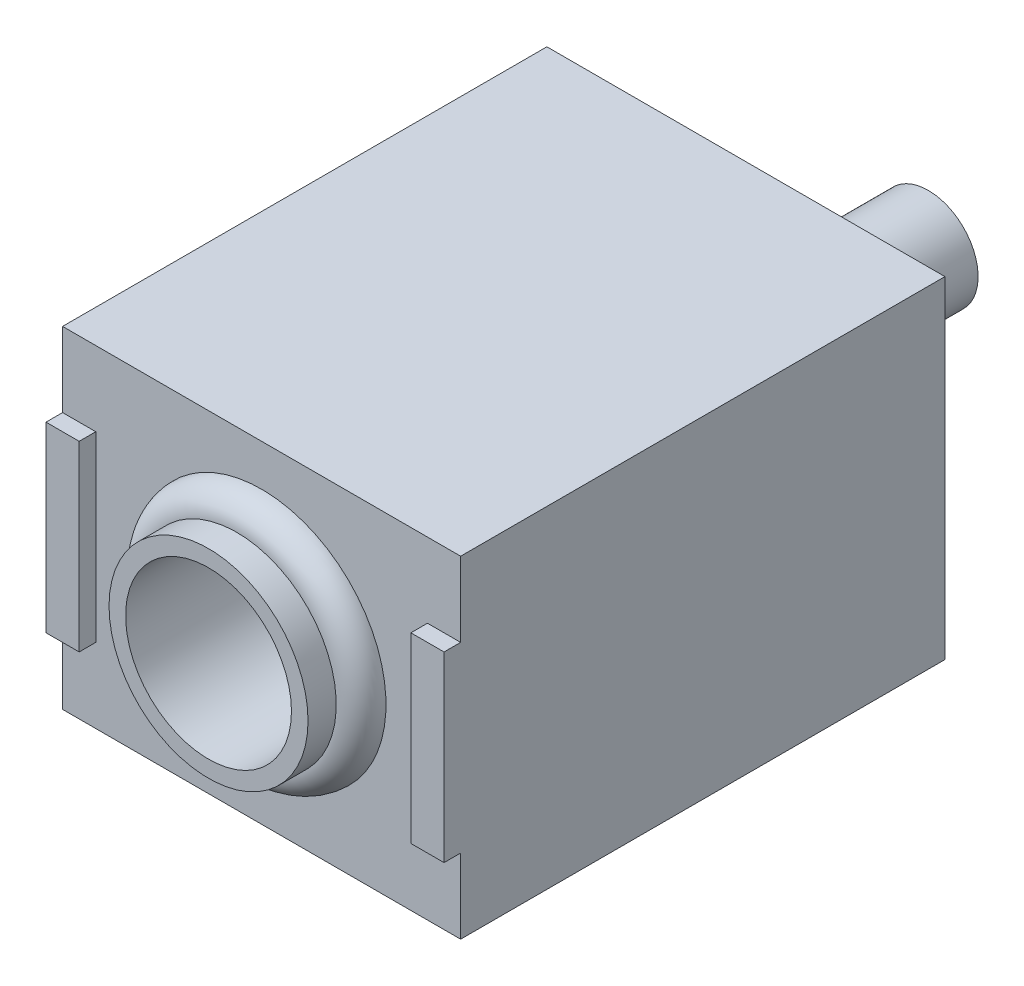
from build123d import *

# Parameters (mm, degrees)
SKETCH1_W           = 12
SKETCH1_H           = 10
BOSS_EXTRUDE1_DEPTH = 14.6
SKETCH2_W           = 1
SKETCH2_H           = 5.5
BOSS_EXTRUDE2_DEPTH = 0.5
SKETCH4_R           = 1.5
BOSS_EXTRUDE3_DEPTH = 5.5
SKETCH5_R           = 2.05
BOSS_EXTRUDE4_DEPTH = 0.5
CUT_EXTRUDE1_DEPTH  = 0.5
SKETCH7_R           = 2.5
CUT_EXTRUDE2_DEPTH  = 11
SKETCH9_R           = 3
SKETCH9_R_2         = 2.5
BOSS_EXTRUDE5_DEPTH = 1.6


with BuildPart() as part:
    # Sketch1 → Boss-Extrude1 (new body)
    with BuildSketch(Plane.XY):
        Rectangle(SKETCH1_W, SKETCH1_H)
    extrude(amount=BOSS_EXTRUDE1_DEPTH)

    # Sketch2 → Boss-Extrude2 (add)
    with BuildSketch(Plane.XY.offset(14.6)):
        with Locations((-5.5, 0)):
            Rectangle(SKETCH2_W, SKETCH2_H)
        with Locations((5.5, 0)):
            Rectangle(SKETCH2_W, SKETCH2_H)
    extrude(amount=BOSS_EXTRUDE2_DEPTH)

    # Sketch4 → Boss-Extrude3 (add)
    with BuildSketch(Plane(origin=(0, 0, 0), x_dir=(-1, 0, 0), z_dir=(0, 0, -1))):
        Circle(SKETCH4_R)
    extrude(amount=BOSS_EXTRUDE3_DEPTH)

    # Sketch5 → Boss-Extrude4 (add)
    with BuildSketch(Plane(origin=(0, 0, 0), x_dir=(-1, 0, 0), z_dir=(0, 0, -1))):
        Circle(SKETCH5_R)
    extrude(amount=BOSS_EXTRUDE4_DEPTH)

    # Sketch6 → Cut-Extrude1 (cut)
    with BuildSketch(Plane(origin=(0, 0, 0), x_dir=(-1, 0, 0), z_dir=(0, 0, -1))):
        with BuildLine():
            Line((-5.022000054, 4.19344844), (-4.356935952, 4.19344844))
            Line((-4.356935952, 4.19344844), (-3.752769285, 2.614121517))
            Line((-3.752769285, 2.614121517), (-3.198682747, 4.19344844))
            Line((-3.198682747, 4.19344844), (-2.534820567, 4.19344844))
            Line((-2.534820567, 4.19344844), (-2.534820567, 4.090884337))
            Line((-2.534820567, 4.090884337), (-2.697080183, 4.090884337))
            add(Edge.make_bspline(
                [(-2.697080183, 4.090884337), (-2.710316809, 4.090636556), (-2.734492679, 4.090183998), (-2.76728752, 4.085652982), (-2.793244282, 4.077989549), (-2.813274161, 4.066597021), (-2.826894921, 4.049870677), (-2.8359508, 4.029264042), (-2.841554988, 4.004099098), (-2.842176045, 3.985816116), (-2.842512875, 3.975900363)],
                knots=[0, 0, 0, 0, 1.461409083, 2.669172297, 3.644102285, 4.438396511, 5.171145089, 5.982913306, 6.9060355, 8, 8, 8, 8], degree=3))
            Line((-2.842512875, 3.975900363), (-2.842512875, 2.394570235))
            add(Edge.make_bspline(
                [(-2.842512875, 2.394570235), (-2.842050819, 2.387038144), (-2.841173668, 2.372739479), (-2.834447891, 2.352433769), (-2.823099881, 2.334952111), (-2.806557353, 2.320282642), (-2.784561689, 2.309069969), (-2.756555778, 2.301303429), (-2.722335078, 2.296750977), (-2.697362885, 2.296271709), (-2.683859029, 2.296012542)],
                knots=[0, 0, 0, 0, 0.852734016, 1.618801414, 2.395714484, 3.189123744, 4.096684287, 5.169862416, 6.469586829, 8, 8, 8, 8], degree=3))
            Line((-2.683859029, 2.296012542), (-2.534820567, 2.296012542))
            Line((-2.534820567, 2.296012542), (-2.534820567, 2.19344844))
            Line((-2.534820567, 2.19344844), (-3.432256465, 2.19344844))
            Line((-3.432256465, 2.19344844), (-3.432256465, 2.296012542))
            Line((-3.432256465, 2.296012542), (-3.265189157, 2.296012542))
            add(Edge.make_bspline(
                [(-3.265189157, 2.296012542), (-3.253950106, 2.296245463), (-3.232932895, 2.296681029), (-3.203686174, 2.301738527), (-3.179094381, 2.310536297), (-3.158974617, 2.322618715), (-3.143443119, 2.337663858), (-3.132382481, 2.354803918), (-3.125466503, 2.374031717), (-3.124871883, 2.387565999), (-3.124564157, 2.394570235)],
                knots=[0, 0, 0, 0, 1.394235928, 2.607244209, 3.666761408, 4.619311681, 5.498637875, 6.326439516, 7.133902247, 8, 8, 8, 8], degree=3))
            Line((-3.124564157, 2.394570235), (-3.124564157, 4.09208626))
            Line((-3.124564157, 4.09208626), (-3.791230824, 2.19344844))
            Line((-3.791230824, 2.19344844), (-3.888987234, 2.19344844))
            Line((-3.888987234, 2.19344844), (-4.611743644, 4.08407344))
            Line((-4.611743644, 4.08407344), (-4.611743644, 2.631349081))
            add(Edge.make_bspline(
                [(-4.611743644, 2.631349081), (-4.611377469, 2.611036444), (-4.610694083, 2.573127352), (-4.605325483, 2.520247499), (-4.596108802, 2.475353065), (-4.582524113, 2.437834201), (-4.564432022, 2.407070341), (-4.544422056, 2.379994045), (-4.520414227, 2.357133819), (-4.492696269, 2.33684315), (-4.45794728, 2.320895889), (-4.41471004, 2.309573563), (-4.362603697, 2.300270875), (-4.324529352, 2.297501845), (-4.304051336, 2.296012542)],
                knots=[0, 0, 0, 0, 1.387005521, 2.588542367, 3.624266538, 4.510231893, 5.298685798, 6.05383917, 6.802021236, 7.553697037, 8.390065714, 9.394768359, 10.598794723, 12, 12, 12, 12], degree=3))
            Line((-4.304051336, 2.296012542), (-4.304051336, 2.19344844))
            Line((-4.304051336, 2.19344844), (-5.022000054, 2.19344844))
            Line((-5.022000054, 2.19344844), (-5.022000054, 2.296012542))
            add(Edge.make_bspline(
                [(-5.022000054, 2.296012542), (-5.007558595, 2.297187721), (-4.97993619, 2.299435504), (-4.940384187, 2.30521534), (-4.904363952, 2.311965762), (-4.872178394, 2.321630139), (-4.843002284, 2.331333401), (-4.818185115, 2.344714342), (-4.796055659, 2.35825151), (-4.778051671, 2.375035374), (-4.762204772, 2.393739353), (-4.7498382, 2.416205607), (-4.738151387, 2.44116405), (-4.729866044, 2.469901954), (-4.722344359, 2.501519512), (-4.718026847, 2.536578835), (-4.714468033, 2.57465227), (-4.714362538, 2.601157074), (-4.714307747, 2.614922799)],
                knots=[0, 0, 0, 0, 1.3499974, 2.582161247, 3.724551801, 4.760625632, 5.713431081, 6.581852865, 7.382807722, 8.122943763, 8.865587329, 9.657594863, 10.504338807, 11.429508857, 12.438001628, 13.531119739, 14.71774469, 16, 16, 16, 16], degree=3))
            Line((-4.714307747, 2.614922799), (-4.714307747, 3.992326645))
            add(Edge.make_bspline(
                [(-4.714307747, 3.992326645), (-4.714667267, 4.000376864), (-4.71534259, 4.015498393), (-4.720947722, 4.036459034), (-4.730366107, 4.054081799), (-4.74431361, 4.06851761), (-4.763922895, 4.079141723), (-4.789389281, 4.085827056), (-4.821001443, 4.090114928), (-4.844231256, 4.090612312), (-4.856935952, 4.090884337)],
                knots=[0, 0, 0, 0, 0.964066467, 1.810902258, 2.577654402, 3.336338785, 4.182417323, 5.216170427, 6.47748631, 8, 8, 8, 8], degree=3))
            Line((-4.856935952, 4.090884337), (-5.022000054, 4.090884337))
            Line((-5.022000054, 4.090884337), (-5.022000054, 4.19344844))
        make_face()
    extrude(amount=-CUT_EXTRUDE1_DEPTH, mode=Mode.SUBTRACT)

    # Sketch7 → Cut-Extrude2 (cut)
    with BuildSketch(Plane.XY.offset(14.6)):
        Circle(SKETCH7_R)
    extrude(amount=-CUT_EXTRUDE2_DEPTH, mode=Mode.SUBTRACT)

    # Sketch9 → Boss-Extrude5 (add)
    with BuildSketch(Plane.XY.offset(14.6)):
        with Locations(Location((0, 0, 0), (0, 0, 180))):
            Circle(SKETCH9_R)
        Circle(SKETCH9_R_2, mode=Mode.SUBTRACT)
    extrude(amount=BOSS_EXTRUDE5_DEPTH)

    # Sketch10 → Revolve1 (revolve)
    with BuildSketch(Plane(origin=(0, 0, 0), x_dir=(1, 0, 0), z_dir=(0, 1, 0)), mode=Mode.PRIVATE) as revolve1_sk:
        with BuildLine():
            Line((3.75, -14.6), (3, -14.6))
            Line((3, -14.6), (3, -15.35))
            ThreePointArc((3, -15.35), (3.530330086, -15.130330086), (3.75, -14.6))
        make_face()
    revolve(revolve1_sk.sketch.rotate(Axis((0, 0, 3.6), (0, 0, 1)), 180), axis=Axis((0, 0, 3.6), (0, 0, 1)))


solid = part.part
